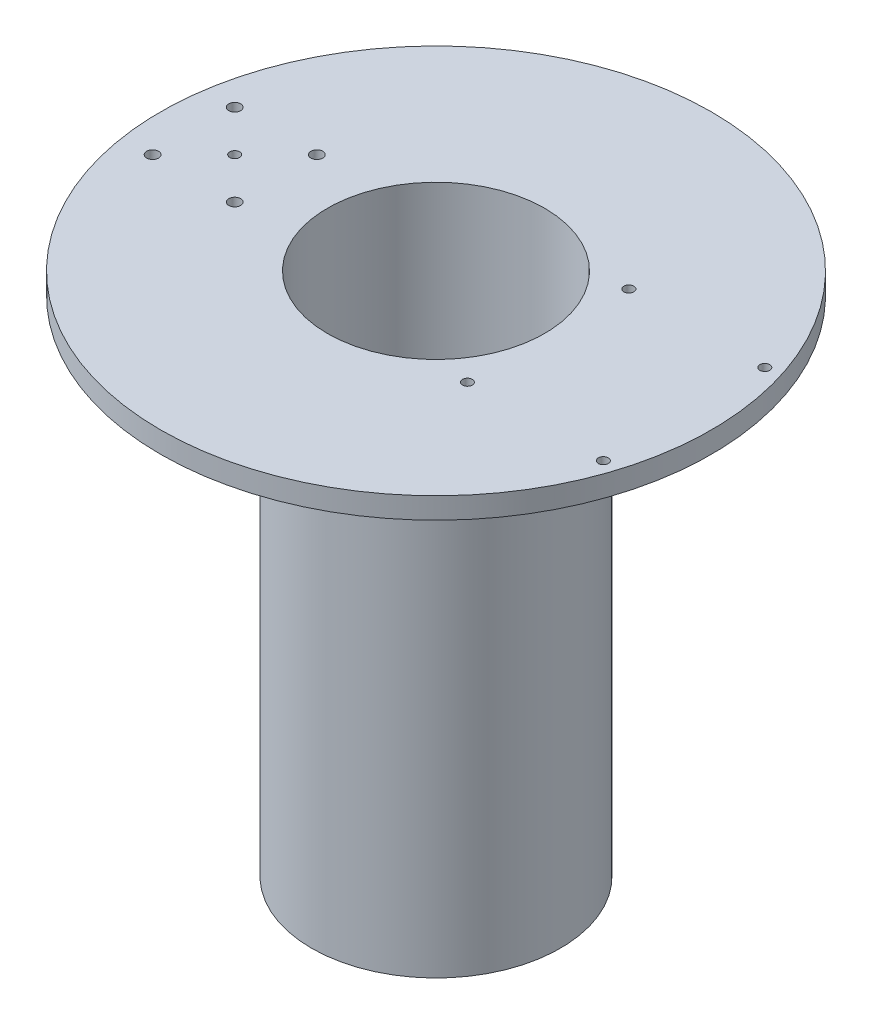
from build123d import *

# Parameters (mm, degrees)
F_10_24_TAPPED_HOLE3_D                      = 3.75000012
F_10_24_TAPPED_HOLE4_D                      = 3.75000012
F_10_24_TAPPED_HOLE5_D                      = 4.499991
CBORE_FOR_M5_CHEESE_HEAD_SCREW1_D           = 5.5
CBORE_FOR_M5_CHEESE_HEAD_SCREW1_CBORE_D     = 9.5
CBORE_FOR_M5_CHEESE_HEAD_SCREW1_CBORE_DEPTH = 3.3


with BuildPart() as part:
    # Sketch1 → Revolve1 (revolve)
    with BuildSketch(Plane.XY):
        Polygon((0, 0), (57, 0), (57, -190), (104, -190), (104, -185), (63, -185), (63, 8), (0, 8), align=None)
    revolve(axis=Axis((104, -190, 0), (0, 1, 0)))

    # #10-24 Tapped Hole3 (through all)
    with Locations(Plane(origin=(0, 8, 0), x_dir=(1, 0, 0), z_dir=(0, 1, 0))):
        with Locations((146.346, 30.48), (197.654, 30.48), (197.654, -30.48), (146.346, -30.48)):
            Hole(F_10_24_TAPPED_HOLE3_D / 2)

    # #10-24 Tapped Hole4 (through all)
    with Locations(Plane(origin=(0, 8, 0), x_dir=(1, 0, 0), z_dir=(0, 1, 0))):
        with Locations((28, 0)):
            Hole(F_10_24_TAPPED_HOLE4_D / 2)

    # #10-24 Tapped Hole5 (through all)
    with Locations(Plane(origin=(0, 8, 0), x_dir=(1, 0, 0), z_dir=(0, 1, 0))):
        with Locations((12.5, 15.5), (43.5, 15.5), (43.5, -15.5), (12.5, -15.5)):
            Hole(F_10_24_TAPPED_HOLE5_D / 2)

    # CBORE for M5 Cheese Head Screw1 (through all)
    with Locations(Plane(origin=(0, -190, 0), x_dir=(-1, 0, 0), z_dir=(0, -1, 0))):
        with Locations((-79, -25), (-79, 25), (-129, 25), (-129, -25)):
            CounterBoreHole(CBORE_FOR_M5_CHEESE_HEAD_SCREW1_D / 2, CBORE_FOR_M5_CHEESE_HEAD_SCREW1_CBORE_D / 2, CBORE_FOR_M5_CHEESE_HEAD_SCREW1_CBORE_DEPTH)


solid = part.part
